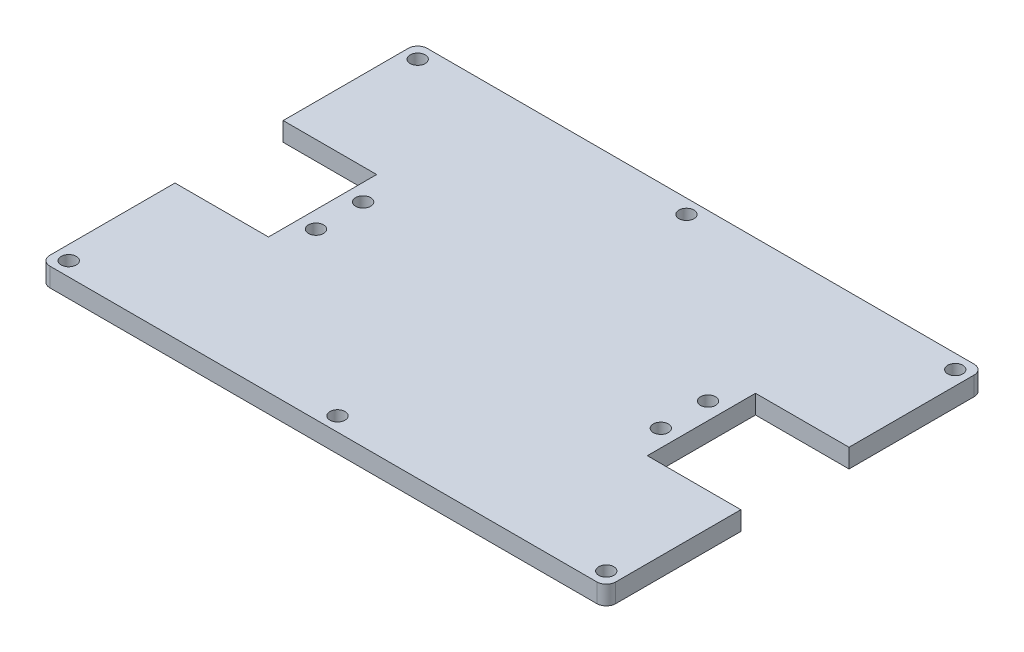
from build123d import *

# Parameters (mm, degrees)
SKETCH2_R           = 1.6
BOSS_EXTRUDE2_DEPTH = 4
FILLET1_R           = 2
FILLET2_R           = 2
FILLET3_R           = 2
FILLET4_R           = 2


with BuildPart() as part:
    # Sketch2 → Boss-Extrude2 (new body)
    with BuildSketch(Plane(origin=(0, 0, 0), x_dir=(1, 0, 0), z_dir=(0, 1, 0))):
        Polygon((0, 28.53), (0, 0), (120, 0), (120, 28.53), (100.17, 28.53), (100.17, 51.47), (120, 51.47), (120, 80), (0, 80), (0, 51.47), (19.83, 51.47), (19.83, 28.53), align=None)
        with Locations((3, 3)):
            Circle(SKETCH2_R, mode=Mode.SUBTRACT)
        with Locations((23.43, 35)):
            Circle(SKETCH2_R, mode=Mode.SUBTRACT)
        with Locations((60, 3)):
            Circle(SKETCH2_R, mode=Mode.SUBTRACT)
        with Locations((117, 3)):
            Circle(SKETCH2_R, mode=Mode.SUBTRACT)
        with Locations((96.57, 35)):
            Circle(SKETCH2_R, mode=Mode.SUBTRACT)
        with Locations((23.43, 45)):
            Circle(SKETCH2_R, mode=Mode.SUBTRACT)
        with Locations((3, 77)):
            Circle(SKETCH2_R, mode=Mode.SUBTRACT)
        with Locations((96.57, 45)):
            Circle(SKETCH2_R, mode=Mode.SUBTRACT)
        with Locations((60, 77)):
            Circle(SKETCH2_R, mode=Mode.SUBTRACT)
        with Locations((117, 77)):
            Circle(SKETCH2_R, mode=Mode.SUBTRACT)
    extrude(amount=BOSS_EXTRUDE2_DEPTH)

    # Fillet1
    fillet1_edges = [part.edges().sort_by_distance(p)[0] for p in [
        (0, 2, -80),
    ]]
    fillet(fillet1_edges, radius=FILLET1_R)

    # Fillet2
    fillet2_edges = [part.edges().sort_by_distance(p)[0] for p in [
        (120, 2, -80),
    ]]
    fillet(fillet2_edges, radius=FILLET2_R)

    # Fillet3
    fillet3_edges = [part.edges().sort_by_distance(p)[0] for p in [
        (120, 2, 0),
    ]]
    fillet(fillet3_edges, radius=FILLET3_R)

    # Fillet4
    fillet4_edges = [part.edges().sort_by_distance(p)[0] for p in [
        (0, 2, 0),
    ]]
    fillet(fillet4_edges, radius=FILLET4_R)


solid = part.part
